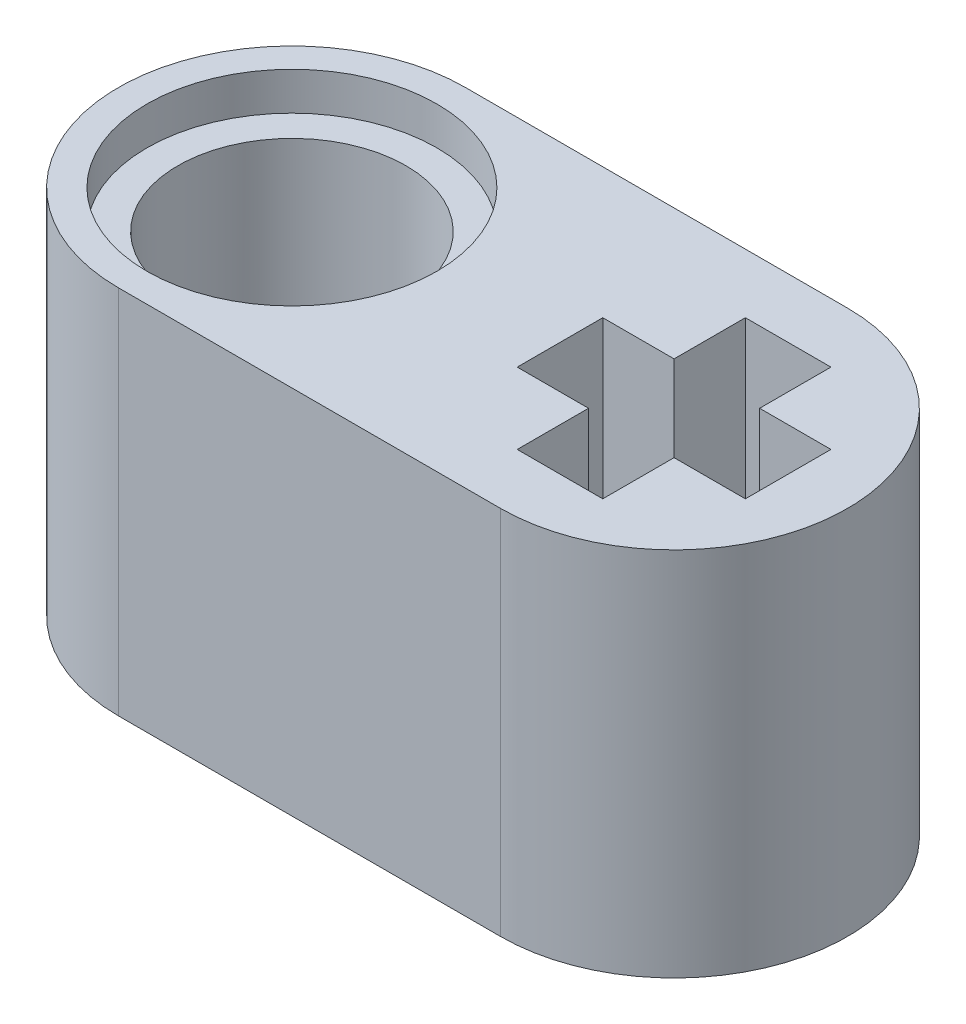
from build123d import *

# Parameters (mm, degrees)
SKETCH1_R           = 2.4
BOSS_EXTRUDE1_DEPTH = 7.8
SKETCH2_R           = 3.05
CUT_EXTRUDE1_DEPTH  = 0.8
SKETCH4_R           = 3.05
CUT_EXTRUDE2_DEPTH  = 0.8


with BuildPart() as part:
    # Sketch1 → Boss-Extrude1 (new body)
    with BuildSketch(Plane(origin=(0, 0, 0), x_dir=(1, 0, 0), z_dir=(0, 1, 0))):
        with BuildLine():
            Line((-4.02, 3.65), (4.02, 3.65))
            ThreePointArc((4.02, 3.65), (7.67, 0), (4.02, -3.65))
            Line((4.02, -3.65), (-4.02, -3.65))
            ThreePointArc((-4.02, -3.65), (-7.67, 0), (-4.02, 3.65))
        make_face()
        with Locations((-4.02, 0)):
            Circle(SKETCH1_R, mode=Mode.SUBTRACT)
        Polygon((3.12, 2.4), (3.12, 0.9), (1.62, 0.9), (1.62, -0.9), (3.12, -0.9), (3.12, -2.4), (4.92, -2.4), (4.92, -0.9), (6.42, -0.9), (6.42, 0.9), (4.92, 0.9), (4.92, 2.4), align=None, mode=Mode.SUBTRACT)
    extrude(amount=BOSS_EXTRUDE1_DEPTH)

    # Sketch2 → Cut-Extrude1 (cut)
    with BuildSketch(Plane(origin=(0, 7.8, 0), x_dir=(1, 0, 0), z_dir=(0, 1, 0))):
        with Locations((-4.02, 0)):
            Circle(SKETCH2_R)
    extrude(amount=-CUT_EXTRUDE1_DEPTH, mode=Mode.SUBTRACT)

    # Sketch4 → Cut-Extrude2 (cut)
    with BuildSketch(Plane.XZ):
        with Locations((-4.02, 0)):
            Circle(SKETCH4_R)
    extrude(amount=-CUT_EXTRUDE2_DEPTH, mode=Mode.SUBTRACT)


solid = part.part
